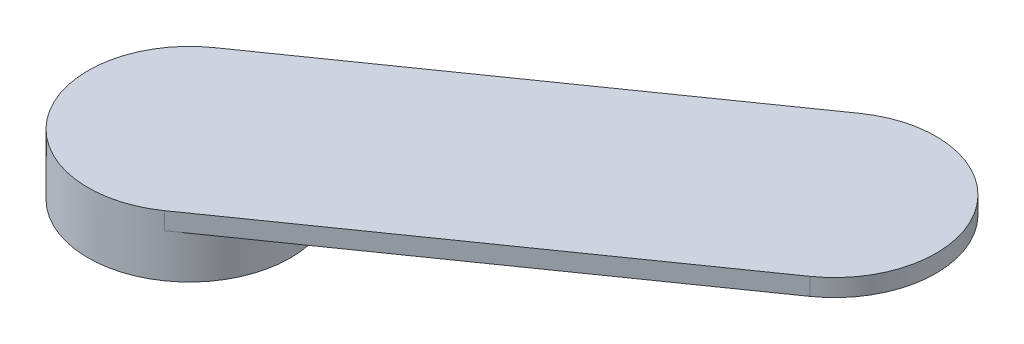
from build123d import *

# Parameters (mm, degrees)
BOSS_EXTRUDE1_DEPTH = 6
SKETCH2_R           = 35
BOSS_EXTRUDE2_DEPTH = 15


with BuildPart() as part:
    # Sketch1 → Boss-Extrude1 (new body)
    with BuildSketch(Plane(origin=(0, 0, 0), x_dir=(1, 0, 0), z_dir=(0, 1, 0))):
        with BuildLine():
            Line((-20.075175272, 28.67032155), (110.989151814, 120.442551366))
            ThreePointArc((110.989151814, 120.442551366), (159.734648636, 111.847405088), (151.139502359, 63.101908266))
            Line((151.139502359, 63.101908266), (20.075175272, -28.67032155))
            ThreePointArc((20.075175272, -28.67032155), (-28.67032155, -20.075175272), (-20.075175272, 28.67032155))
        make_face()
    extrude(amount=-BOSS_EXTRUDE1_DEPTH)

    # Sketch2 → Boss-Extrude2 (add)
    with BuildSketch(Plane.XZ.offset(6)):
        Circle(SKETCH2_R)
    extrude(amount=BOSS_EXTRUDE2_DEPTH)


solid = part.part
